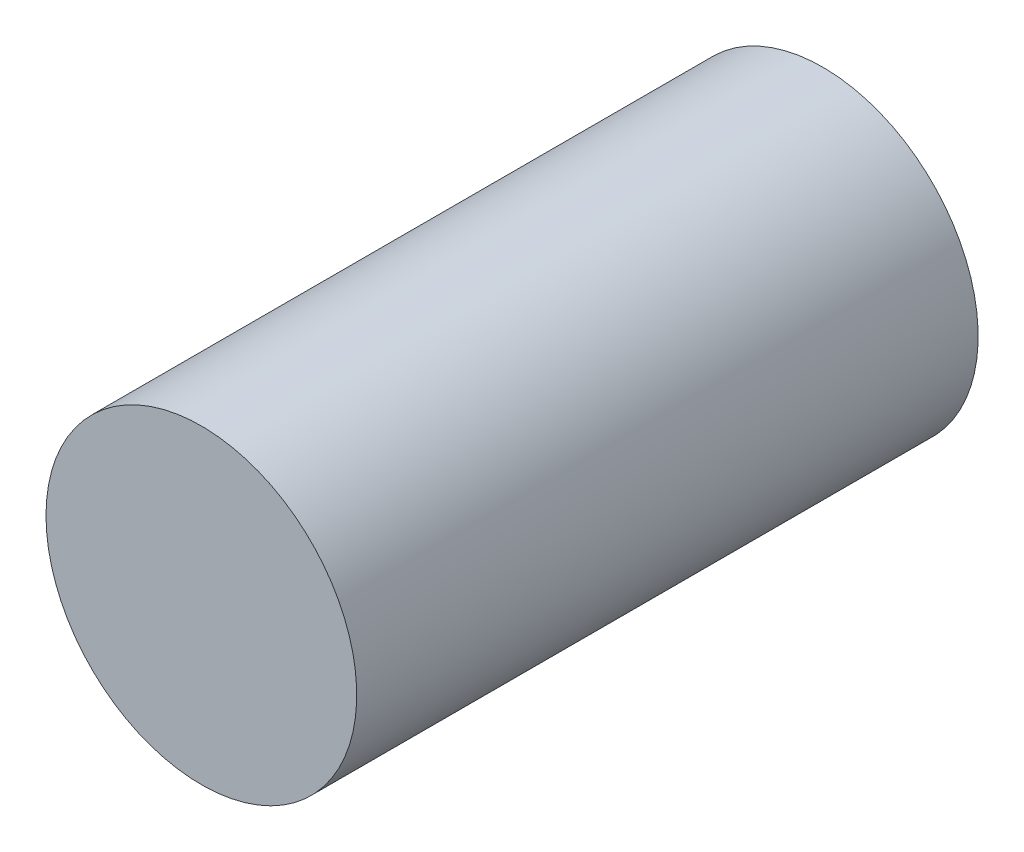
from build123d import *

# Parameters (mm, degrees)
SKETCH1_W = 304.8
SKETCH1_H = 1219.2


with BuildPart() as part:
    # Sketch1 → Revolve1 (revolve)
    with BuildSketch(Plane(origin=(0, 0, 0), x_dir=(1, 0, 0), z_dir=(0, 1, 0))):
        with Locations((152.4, 555.740716298)):
            Rectangle(SKETCH1_W, SKETCH1_H)
    revolve(axis=Axis((0, 0, -1165.340716298), (0, 0, 1)))


solid = part.part
